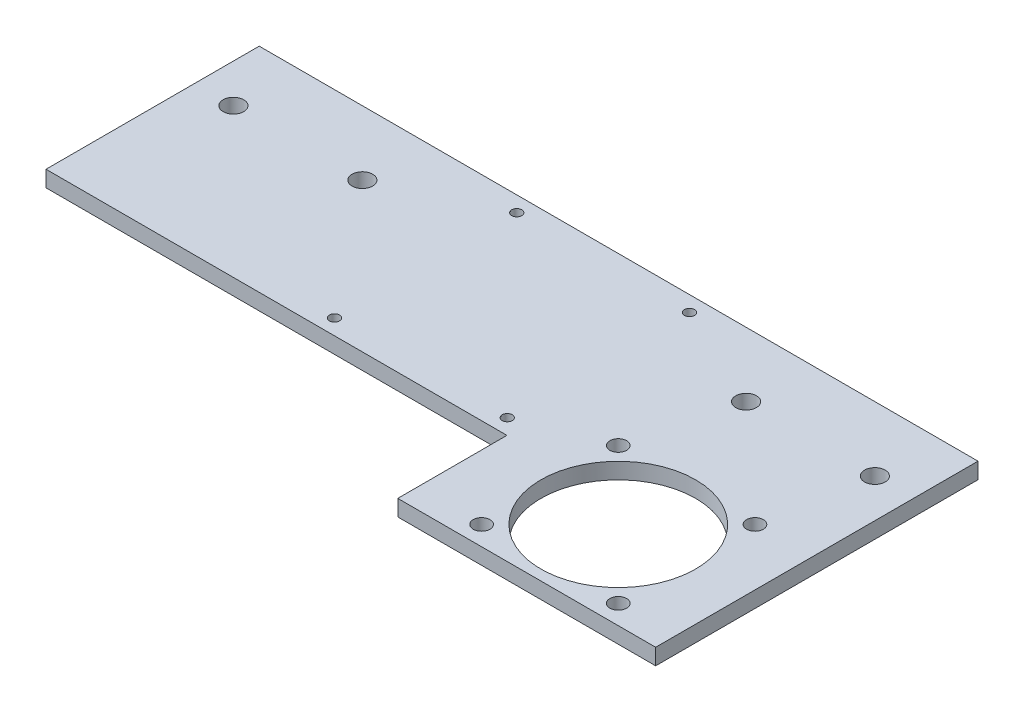
from build123d import *

# Parameters (mm, degrees)
SKETCH1_W               = 40
SKETCH1_H               = 42
BOSS_EXTRUDE1_DEPTH     = 3.175
SKETCH2_R               = 1
CUT_EXTRUDE1_DEPTH      = 4.175
SKETCH3_W               = 50.8
SKETCH3_H               = 63.5
BOSS_EXTRUDE2_DEPTH     = 3.175
SKETCH4_R               = 2.032
CUT_EXTRUDE2_DEPTH      = 4.175
SKETCH8_R               = 1.651
CUT_EXTRUDE5_DEPTH      = 4.175
SKETCH9_R               = 15.24
CUT_EXTRUDE6_DEPTH      = 4.175
SKETCH10_W              = 50.8
SKETCH10_H              = 21.5
CUT_EXTRUDE7_DEPTH      = 1
CUT_EXTRUDE7_DEPTH_BACK = 4.175


with BuildPart() as part:
    # Sketch1 → Boss-Extrude1 (new body)
    with BuildSketch(Plane(origin=(0, 0, 0), x_dir=(1, 0, 0), z_dir=(0, 1, 0))):
        Rectangle(SKETCH1_W, SKETCH1_H)
    extrude(amount=BOSS_EXTRUDE1_DEPTH)

    # Sketch2 → Cut-Extrude1 (cut, through all)
    with BuildSketch(Plane(origin=(0, 3.175, 0), x_dir=(1, 0, 0), z_dir=(0, 1, 0))):
        with Locations((17.015999872, -17.952)):
            Circle(SKETCH2_R)
        with Locations((-17.015999872, -17.952)):
            Circle(SKETCH2_R)
        with Locations((17.015999872, 17.952)):
            Circle(SKETCH2_R)
        with Locations((-17.015999872, 17.952)):
            Circle(SKETCH2_R)
    extrude(amount=-CUT_EXTRUDE1_DEPTH, mode=Mode.SUBTRACT)

    # Sketch3 → Boss-Extrude2 (add)
    with BuildSketch(Plane(origin=(0, 3.175, 0), x_dir=(1, 0, 0), z_dir=(0, 1, 0))):
        with Locations((45.4, -10.75)):
            Rectangle(SKETCH3_W, SKETCH3_H)
        with Locations((-45.4, -10.75)):
            Rectangle(SKETCH3_W, SKETCH3_H)
    extrude(amount=-BOSS_EXTRUDE2_DEPTH)

    # Sketch4 → Cut-Extrude2 (cut, through all)
    with BuildSketch(Plane(origin=(0, 3.175, 0), x_dir=(1, 0, 0), z_dir=(0, 1, 0))):
        with Locations((63.18, 8.3)):
            Circle(SKETCH4_R)
        with Locations((37.814543867, 8.3)):
            Circle(SKETCH4_R)
        with Locations((-37.78, 8.3)):
            Circle(SKETCH4_R)
        with Locations((-63.18, 8.3)):
            Circle(SKETCH4_R)
    extrude(amount=-CUT_EXTRUDE2_DEPTH, mode=Mode.SUBTRACT)

    # Sketch8 → Cut-Extrude5 (cut, through all)
    with BuildSketch(Plane(origin=(0, 0, 0), x_dir=(-1, 0, 0), z_dir=(0, -1, 0))):
        with Locations((-32.7, -38.69)):
            Circle(SKETCH8_R)
        with Locations((-32.7, -11.766)):
            Circle(SKETCH8_R)
        with Locations((-59.624, -38.69)):
            Circle(SKETCH8_R)
        with Locations((-59.624, -11.766)):
            Circle(SKETCH8_R)
    extrude(amount=-CUT_EXTRUDE5_DEPTH, mode=Mode.SUBTRACT)

    # Sketch9 → Cut-Extrude6 (cut, through all)
    with BuildSketch(Plane(origin=(0, 0, 0), x_dir=(-1, 0, 0), z_dir=(0, -1, 0))):
        with Locations((-46.162, -25.228)):
            Circle(SKETCH9_R)
    extrude(amount=-CUT_EXTRUDE6_DEPTH, mode=Mode.SUBTRACT)

    # Sketch10 → Cut-Extrude7 (cut, two sides)
    with BuildSketch(Plane(origin=(0, 3.175, 0), x_dir=(1, 0, 0), z_dir=(0, 1, 0))) as cut_extrude7_sk:
        with Locations((-45.4, -31.75)):
            Rectangle(SKETCH10_W, SKETCH10_H)
    extrude(amount=CUT_EXTRUDE7_DEPTH, mode=Mode.SUBTRACT)
    extrude(cut_extrude7_sk.sketch, amount=-CUT_EXTRUDE7_DEPTH_BACK, mode=Mode.SUBTRACT)


solid = part.part
